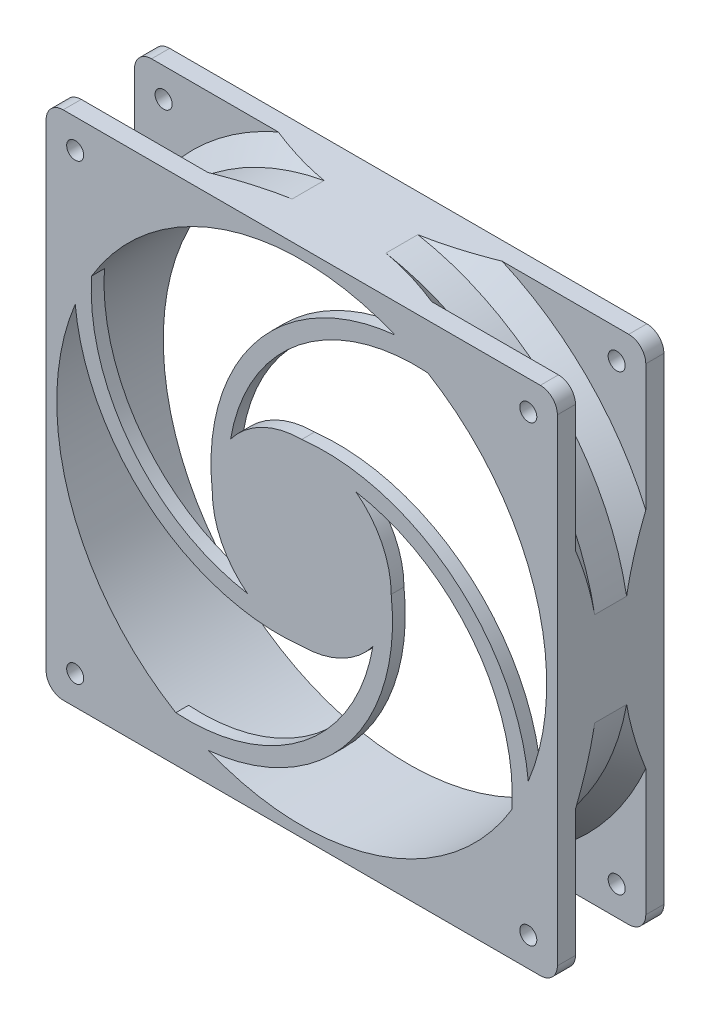
from build123d import *

# Parameters (mm, degrees)
SKETCH1_W           = 120
SKETCH1_H           = 120
SKETCH1_R           = 57.5
BOSS_EXTRUDE1_DEPTH = 25
FILLET1_R           = 4
SKETCH3_R           = 2
CUT_EXTRUDE1_DEPTH  = 26
BOSS_EXTRUDE2_DEPTH = 3


with BuildPart() as part:
    # Sketch1 → Boss-Extrude1 (new body)
    with BuildSketch(Plane.XY):
        Rectangle(SKETCH1_W, SKETCH1_H)
        Circle(SKETCH1_R, mode=Mode.SUBTRACT)
    extrude(amount=BOSS_EXTRUDE1_DEPTH)

    # Fillet1
    fillet1_edges = [part.edges().sort_by_distance(p)[0] for p in [
        (-60, 60, 12.5),
        (60, 60, 12.5),
        (60, -60, 12.5),
        (-60, -60, 12.5),
    ]]
    fillet(fillet1_edges, radius=FILLET1_R)

    # Sketch2 → Cut-Revolve1 (revolve, cut)
    with BuildSketch(Plane(origin=(0, 0, 0), x_dir=(1, 0, 0), z_dir=(0, 1, 0))):
        Polygon((61, -8.75), (61, -16.25), (65.5, -20.75), (86, -20.75), (86, -4.25), (65.5, -4.25), align=None)
    revolve(axis=Axis((0, 0, 0), (0, 0, 1)), mode=Mode.SUBTRACT)

    # Sketch3 → Cut-Extrude1 (cut, through all)
    with BuildSketch(Plane(origin=(0, 0, 0), x_dir=(-1, 0, 0), z_dir=(0, 0, -1))):
        with Locations((-53.171572875, 53.171572875)):
            Circle(SKETCH3_R)
        with Locations((53.171572875, 53.171572875)):
            Circle(SKETCH3_R)
        with Locations((53.171572875, -53.171572875)):
            Circle(SKETCH3_R)
        with Locations((-53.171572875, -53.171572875)):
            Circle(SKETCH3_R)
    extrude(amount=-CUT_EXTRUDE1_DEPTH, mode=Mode.SUBTRACT)

    # Sketch4 → Boss-Extrude2 (add)
    with BuildSketch(Plane.XY.offset(25)):
        with BuildLine():
            ThreePointArc((0, 21), (-9.310739966, 18.823127298), (-16.691166059, 12.743821075))
            ThreePointArc((-16.691166059, 12.743821075), (-0.598422961, 39.925677295), (29.560959215, 49.319364252))
            ThreePointArc((29.560959215, 49.319364252), (25.795909203, 51.388919704), (21.886841663, 53.171572875))
            ThreePointArc((21.886841663, 53.171572875), (-10.667756929, 35.547780517), (-21, 0))
            ThreePointArc((-21, 0), (-18.823127298, -9.310739966), (-12.743821075, -16.691166059))
            ThreePointArc((-12.743821075, -16.691166059), (-39.925677295, -0.598422961), (-49.319364252, 29.560959215))
            ThreePointArc((-49.319364252, 29.560959215), (-51.388919704, 25.795909203), (-53.171572875, 21.886841663))
            ThreePointArc((-53.171572875, 21.886841663), (-35.547780517, -10.667756929), (0, -21))
            ThreePointArc((0, -21), (9.310739966, -18.823127298), (16.691166059, -12.743821075))
            ThreePointArc((16.691166059, -12.743821075), (0.598422961, -39.925677295), (-29.560959215, -49.319364252))
            ThreePointArc((-29.560959215, -49.319364252), (-25.795909203, -51.388919704), (-21.886841663, -53.171572875))
            ThreePointArc((-21.886841663, -53.171572875), (10.667756929, -35.547780517), (21, 0))
            ThreePointArc((21, 0), (18.823127298, 9.310739966), (12.743821075, 16.691166059))
            ThreePointArc((12.743821075, 16.691166059), (39.925677295, 0.598422961), (49.319364252, -29.560959215))
            ThreePointArc((49.319364252, -29.560959215), (51.388919704, -25.795909203), (53.171572875, -21.886841663))
            ThreePointArc((53.171572875, -21.886841663), (35.547780517, 10.667756929), (0, 21))
        make_face()
    extrude(amount=-BOSS_EXTRUDE2_DEPTH)


solid = part.part
